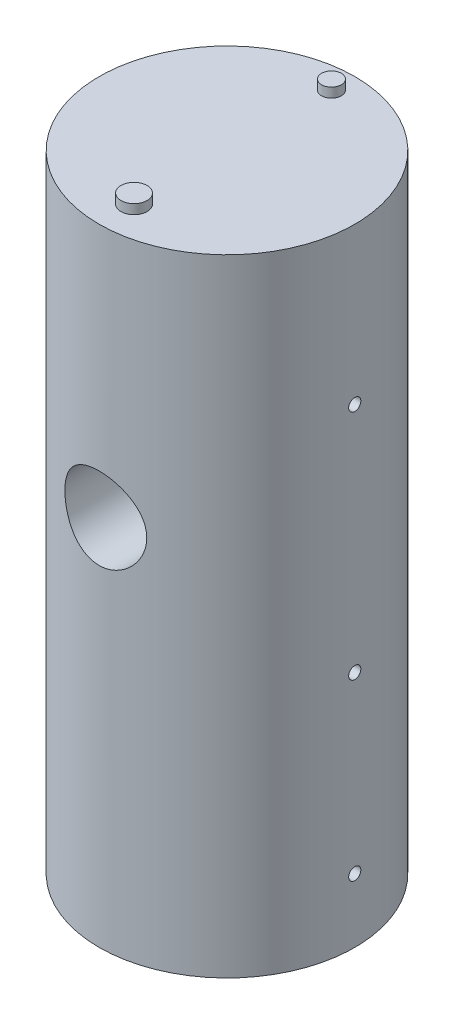
from build123d import *

# Parameters (mm, degrees)
SKETCH1_R           = 50.8
BOSS_EXTRUDE1_DEPTH = 248.79
SKETCH3_R           = 16.256
CUT_EXTRUDE1_DEPTH  = 25.4
SKETCH4_R           = 2.413
CUT_EXTRUDE2_DEPTH  = 102.6000001
SKETCH5_R           = 3.935994996
SKETCH5_R_2         = 5.186201194
BOSS_EXTRUDE2_DEPTH = 3.81


with BuildPart() as part:
    # Sketch1 → Boss-Extrude1 (new body)
    with BuildSketch(Plane(origin=(0, 0, 0), x_dir=(1, 0, 0), z_dir=(0, 1, 0))):
        Circle(SKETCH1_R)
    extrude(amount=BOSS_EXTRUDE1_DEPTH)

    # Sketch3 → Cut-Extrude1 (cut)
    with BuildSketch(Plane.XY.offset(50.8)):
        with Locations((0, 147.668)):
            Circle(SKETCH3_R)
    extrude(amount=-CUT_EXTRUDE1_DEPTH, mode=Mode.SUBTRACT)

    # Sketch4 → Cut-Extrude2 (cut, through all)
    with BuildSketch(Plane(origin=(50.8, 0, 0), x_dir=(0, 0, -1), z_dir=(1, 0, 0))):
        with Locations((0, 186.79)):
            Circle(SKETCH4_R)
        with Locations((0, 94.58)):
            Circle(SKETCH4_R)
        with Locations((0, 25.4)):
            Circle(SKETCH4_R)
    extrude(amount=-CUT_EXTRUDE2_DEPTH, mode=Mode.SUBTRACT)

    # Sketch5 → Boss-Extrude2 (add)
    with BuildSketch(Plane(origin=(0, 248.79, 0), x_dir=(1, 0, 0), z_dir=(0, 1, 0))):
        with Locations((0, 41.48960955)):
            Circle(SKETCH5_R)
        with Locations((0, -36.918720362)):
            Circle(SKETCH5_R_2)
    extrude(amount=BOSS_EXTRUDE2_DEPTH)


solid = part.part
